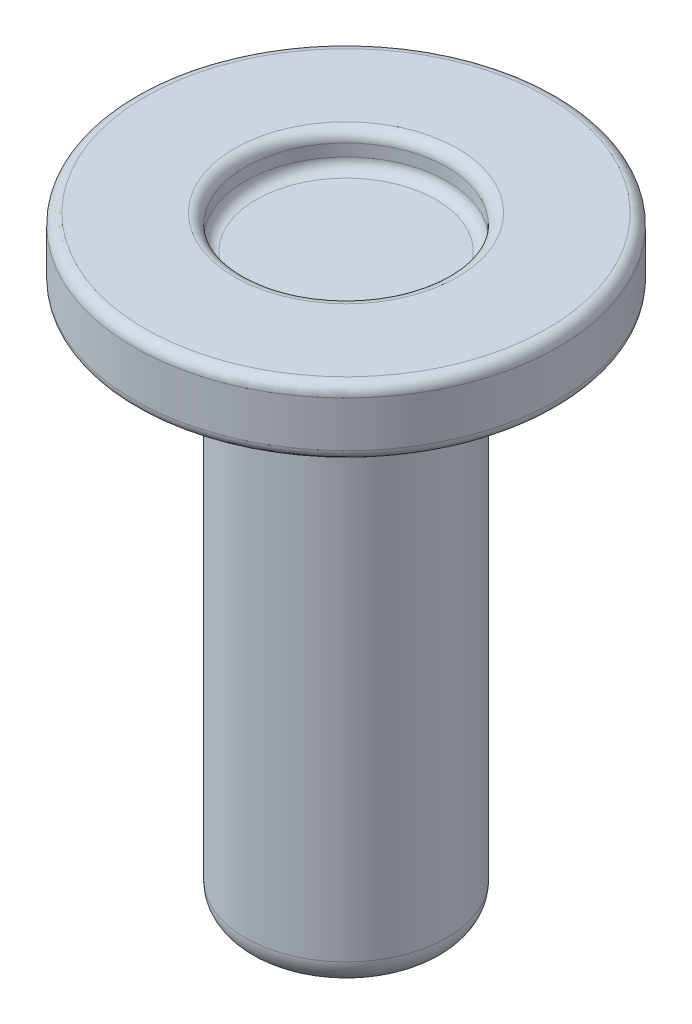
from build123d import *


with BuildPart() as part:
    # Sketch1 → Revolve1 (revolve)
    with BuildSketch(Plane.XY):
        with BuildLine():
            Line((0, 0), (-2.12725, 0))
            ThreePointArc((-2.12725, 0), (-2.306855122, 0.074394878), (-2.38125, 0.254))
            Line((-2.38125, 0.254), (-2.38125, 0.53975))
            ThreePointArc((-2.38125, 0.53975), (-2.455644878, 0.719355122), (-2.63525, 0.79375))
            Line((-2.63525, 0.79375), (-4.7498, 0.79375))
            ThreePointArc((-4.7498, 0.79375), (-4.929405122, 0.719355122), (-5.0038, 0.53975))
            Line((-5.0038, 0.53975), (-5.0038, -0.53975))
            ThreePointArc((-5.0038, -0.53975), (-4.929405122, -0.719355122), (-4.7498, -0.79375))
            Line((-4.7498, -0.79375), (-2.63525, -0.79375))
            ThreePointArc((-2.63525, -0.79375), (-2.455644878, -0.868144878), (-2.38125, -1.04775))
            Line((-2.38125, -1.04775), (-2.38125, -12.85875))
            ThreePointArc((-2.38125, -12.85875), (-2.195262806, -13.307762806), (-1.74625, -13.49375))
            Line((-1.74625, -13.49375), (0, -13.49375))
            Line((0, -13.49375), (0, 0))
        make_face()
    revolve(axis=Axis((0, -13.49375, 0), (0, 1, 0)))


solid = part.part
